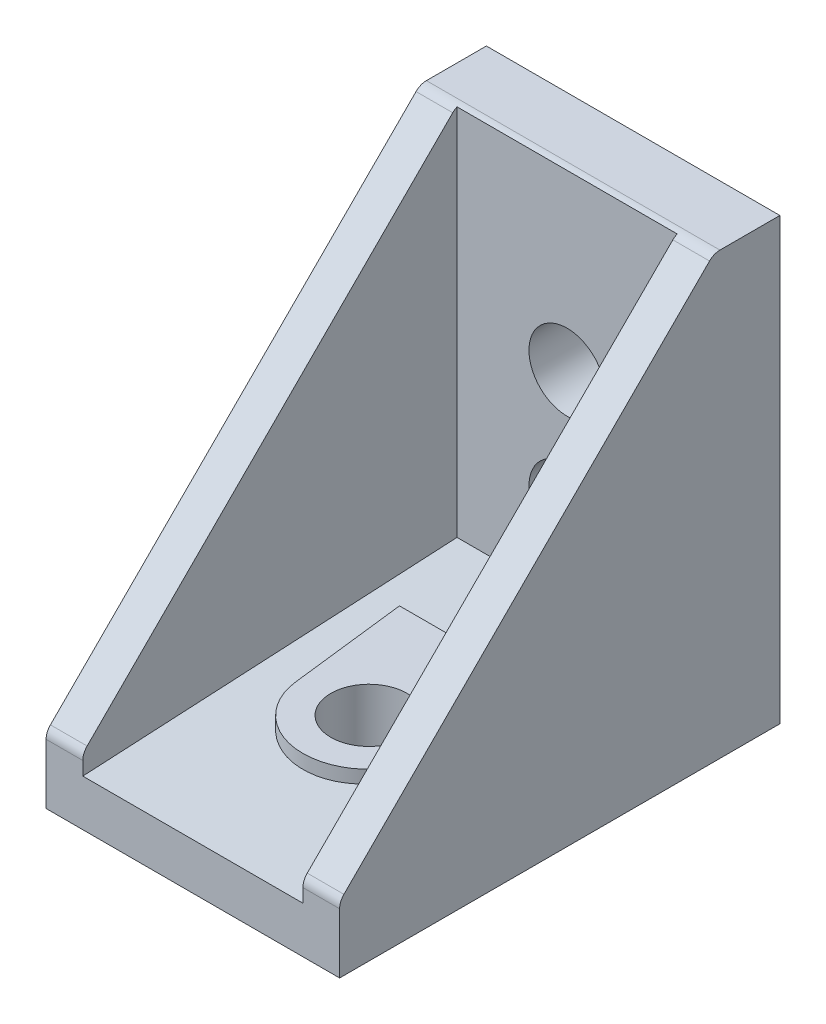
from build123d import *

# Parameters (mm, degrees)
EXTRUDE_1_DEPTH          = 10
EXTRUDE_1_DEPTH_BACK     = 10
CUT_EXTRUDE_1_DEPTH      = 7.5
CUT_EXTRUDE_1_DEPTH_BACK = 7.5
EXTRUDE_2_DEPTH          = 2.25
SKETCH_4_R               = 2.6
CUT_EXTRUDE_2_DEPTH      = 4.5
SKETCH_5_R               = 2.6
CUT_EXTRUDE_3_DEPTH      = 4.5
SKETCH_6_R               = 2.6
CUT_EXTRUDE_4_DEPTH      = 4.5
SKETCH_7_W               = 20
SKETCH_7_H               = 30
EXTRUDE_3_DEPTH          = 1
SKETCH_8_W               = 20
SKETCH_8_H               = 30
CUT_EXTRUDE_5_DEPTH      = 1


with BuildPart() as part:
    # ｽｹｯﾁ1 → ﾎﾞｽ - 押し出し1 (new, two sides: drawn at the far end of the back side and taken through both)
    with BuildSketch(Plane(origin=(0, 0, 0), x_dir=(0, 0, -1), z_dir=(1, 0, 0)).offset(-EXTRUDE_1_DEPTH_BACK)):
        with BuildLine():
            Line((-30, 4.085786438), (-30, 0))
            Line((-30, 0), (0, 0))
            Line((0, 0), (0, 30))
            Line((0, 30), (-4.085786438, 30))
            ThreePointArc((-4.085786438, 30), (-4.46846987, 29.923879533), (-4.792893219, 29.707106781))
            Line((-4.792893219, 29.707106781), (-29.707106781, 4.792893219))
            ThreePointArc((-29.707106781, 4.792893219), (-29.923879533, 4.46846987), (-30, 4.085786438))
        make_face()
    extrude(amount=EXTRUDE_1_DEPTH + EXTRUDE_1_DEPTH_BACK)

    # ｽｹｯﾁ2 → ｶｯﾄ - 押し出し1 (cut, two sides: drawn at the far end of the back side and taken through both)
    with BuildSketch(Plane(origin=(0, 0, 0), x_dir=(0, 0, -1), z_dir=(1, 0, 0)).offset(-CUT_EXTRUDE_1_DEPTH_BACK)):
        Polygon((-34.5, 34.5), (-34.5, 2.927766622), (-4.5, 4.5), (-4.5, 34.5), align=None)
    extrude(amount=CUT_EXTRUDE_1_DEPTH + CUT_EXTRUDE_1_DEPTH_BACK, mode=Mode.SUBTRACT)

    # ｽｹｯﾁ3 → ﾎﾞｽ - 押し出し2 (add)
    with BuildSketch(Plane(origin=(0, 4.5, 0), x_dir=(1, 0, 0), z_dir=(0, 1, 0))):
        with BuildLine():
            Line((-5.420884207, -10.5), (-4.4686916, -18.529901296))
            ThreePointArc((-4.4686916, -18.529901296), (0, -22.5), (4.4686916, -18.529901296))
            Line((4.4686916, -18.529901296), (5.420884207, -10.5))
            Line((5.420884207, -10.5), (-5.420884207, -10.5))
        make_face()
    extrude(amount=-EXTRUDE_2_DEPTH)

    # ｽｹｯﾁ4 → ｶｯﾄ - 押し出し2 (cut)
    with BuildSketch(Plane.XY):
        with Locations((0, 18)):
            Circle(SKETCH_4_R)
    extrude(amount=CUT_EXTRUDE_2_DEPTH, mode=Mode.SUBTRACT)

    # ｽｹｯﾁ5 → ｶｯﾄ - 押し出し3 (cut)
    with BuildSketch(Plane.XY):
        with Locations((0, 10)):
            Circle(SKETCH_5_R)
    extrude(amount=CUT_EXTRUDE_3_DEPTH, mode=Mode.SUBTRACT)

    # ｽｹｯﾁ6 → ｶｯﾄ - 押し出し4 (cut)
    with BuildSketch(Plane(origin=(0, 0, 0), x_dir=(1, 0, 0), z_dir=(0, 1, 0))):
        with Locations((0, -18)):
            Circle(SKETCH_6_R)
    extrude(amount=CUT_EXTRUDE_4_DEPTH, mode=Mode.SUBTRACT)

    # ｽｹｯﾁ7 → ﾎﾞｽ - 押し出し3 (add)
    with BuildSketch(Plane(origin=(0, 0, 0), x_dir=(1, 0, 0), z_dir=(0, 1, 0))):
        with Locations((0, -15)):
            Rectangle(SKETCH_7_W, SKETCH_7_H)
    extrude(amount=-EXTRUDE_3_DEPTH)

    # ｽｹｯﾁ8 → ｶｯﾄ - 押し出し5 (cut)
    with BuildSketch(Plane(origin=(0, 0, 0), x_dir=(1, 0, 0), z_dir=(0, 1, 0))):
        with Locations((0, -15)):
            Rectangle(SKETCH_8_W, SKETCH_8_H)
        with BuildLine():
            Line((-3, -24.3), (-3, -26.7))
            ThreePointArc((-3, -26.7), (-2.912132034, -26.912132034), (-2.7, -27))
            Line((-2.7, -27), (2.7, -27))
            ThreePointArc((2.7, -27), (2.912132034, -26.912132034), (3, -26.7))
            Line((3, -26.7), (3, -24.3))
            ThreePointArc((3, -24.3), (2.912132034, -24.087867966), (2.7, -24))
            Line((2.7, -24), (-2.7, -24))
            ThreePointArc((-2.7, -24), (-2.912132034, -24.087867966), (-3, -24.3))
        make_face(mode=Mode.SUBTRACT)
        with BuildLine():
            Line((-3, -5.3), (-3, -10.7))
            ThreePointArc((-3, -10.7), (-2.912132034, -10.912132034), (-2.7, -11))
            Line((-2.7, -11), (2.7, -11))
            ThreePointArc((2.7, -11), (2.912132034, -10.912132034), (3, -10.7))
            Line((3, -10.7), (3, -5.3))
            ThreePointArc((3, -5.3), (2.912132034, -5.087867966), (2.7, -5))
            Line((2.7, -5), (-2.7, -5))
            ThreePointArc((-2.7, -5), (-2.912132034, -5.087867966), (-3, -5.3))
        make_face(mode=Mode.SUBTRACT)
    extrude(amount=-CUT_EXTRUDE_5_DEPTH, mode=Mode.SUBTRACT)


solid = part.part
